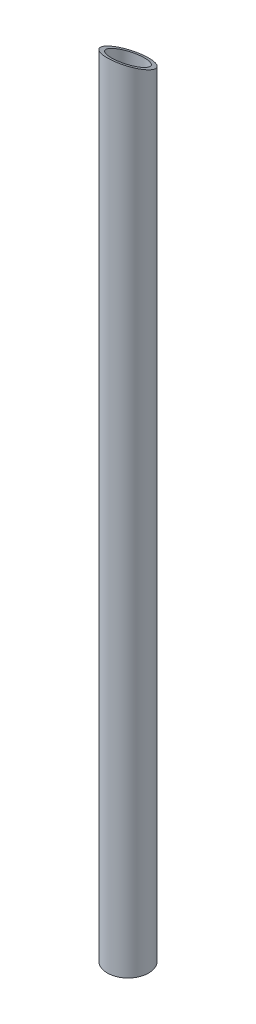
from build123d import *

# Parameters (mm, degrees)
SKETCH1_R               = 15.9
SKETCH1_R_2             = 12.725
BOSS_EXTRUDE1_DEPTH     = 609.6
CUT_EXTRUDE1_DEPTH      = 16.9
CUT_EXTRUDE1_DEPTH_BACK = 16.9


with BuildPart() as part:
    # Sketch1 → Boss-Extrude1 (new body)
    with BuildSketch(Plane(origin=(0, 0, 0), x_dir=(1, 0, 0), z_dir=(0, 1, 0))):
        Circle(SKETCH1_R)
        Circle(SKETCH1_R_2, mode=Mode.SUBTRACT)
    extrude(amount=BOSS_EXTRUDE1_DEPTH)

    # Sketch2 → Cut-Extrude1 (cut, two sides)
    with BuildSketch(Plane(origin=(0, 0, 0), x_dir=(0, 0, -1), z_dir=(1, 0, 0))) as cut_extrude1_sk:
        Polygon((15.9, 609.6), (-15.9, 609.6), (15.9, 593.7), align=None)
    extrude(amount=CUT_EXTRUDE1_DEPTH, mode=Mode.SUBTRACT)
    extrude(cut_extrude1_sk.sketch, amount=-CUT_EXTRUDE1_DEPTH_BACK, mode=Mode.SUBTRACT)


solid = part.part
